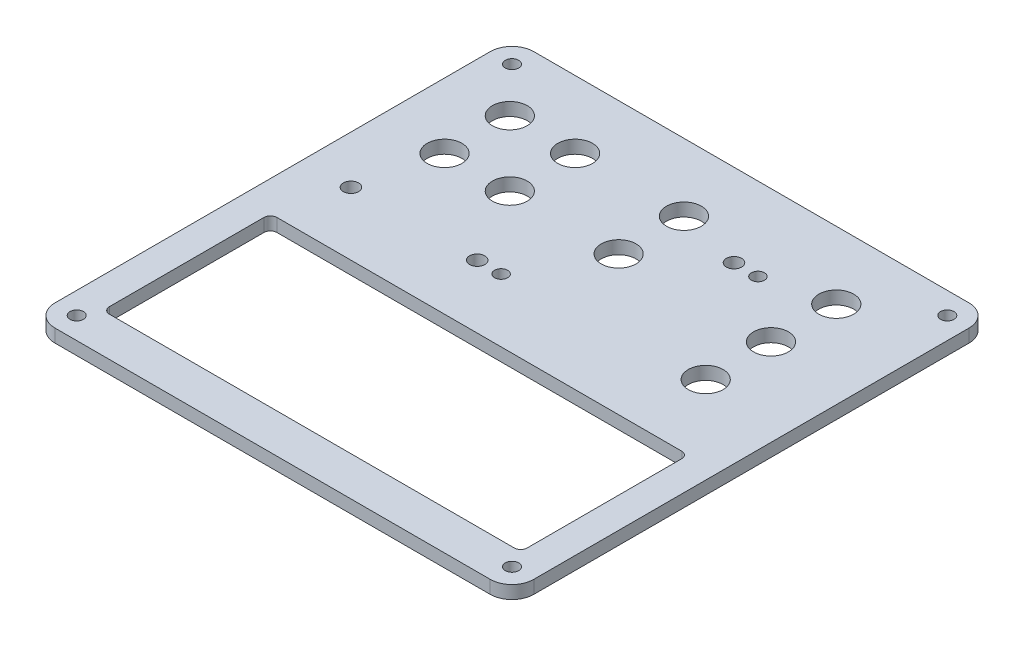
from build123d import *

# Parameters (mm, degrees)
SKETCH1_W           = 110
SKETCH1_H           = 110
SKETCH1_R           = 1.55
BOSS_EXTRUDE1_DEPTH = 3
FILLET1_R           = 5
SKETCH2_W           = 96
SKETCH2_H           = 38.5
CUT_EXTRUDE1_DEPTH  = 78.839578622
FILLET2_R           = 1.5
SKETCH3_R           = 4
CUT_EXTRUDE2_DEPTH  = 78.839578622
SKETCH4_R           = 1.75
SKETCH4_R_2         = 1.5
CUT_EXTRUDE3_DEPTH  = 78.839578622


with BuildPart() as part:
    # Sketch1 → Boss-Extrude1 (new body)
    with BuildSketch(Plane(origin=(0, 0, 0), x_dir=(1, 0, 0), z_dir=(0, 1, 0))):
        Rectangle(SKETCH1_W, SKETCH1_H)
        with Locations((-50, 50)):
            Circle(SKETCH1_R, mode=Mode.SUBTRACT)
        with Locations((50, 50)):
            Circle(SKETCH1_R, mode=Mode.SUBTRACT)
        with Locations((50, -50)):
            Circle(SKETCH1_R, mode=Mode.SUBTRACT)
        with Locations((-50, -50)):
            Circle(SKETCH1_R, mode=Mode.SUBTRACT)
    extrude(amount=BOSS_EXTRUDE1_DEPTH)

    # Fillet1
    fillet1_edges = [part.edges().sort_by_distance(p)[0] for p in [
        (-55, 1.5, -55),
        (55, 1.5, -55),
        (55, 1.5, 55),
        (-55, 1.5, 55),
    ]]
    fillet(fillet1_edges, radius=FILLET1_R)

    # Sketch2 → Cut-Extrude1 (cut, through all)
    with BuildSketch(Plane(origin=(0, 3, 0), x_dir=(1, 0, 0), z_dir=(0, 1, 0))):
        with Locations((0, -26.75)):
            Rectangle(SKETCH2_W, SKETCH2_H)
    extrude(amount=-CUT_EXTRUDE1_DEPTH, mode=Mode.SUBTRACT)

    # Fillet2
    fillet2_edges = [part.edges().sort_by_distance(p)[0] for p in [
        (-48, 1.5, 46),
        (48, 1.5, 46),
        (48, 1.5, 7.5),
        (-48, 1.5, 7.5),
    ]]
    fillet(fillet2_edges, radius=FILLET2_R)

    # Sketch3 → Cut-Extrude2 (cut, through all)
    with BuildSketch(Plane(origin=(0, 3, 0), x_dir=(1, 0, 0), z_dir=(0, 1, 0))):
        with Locations((-40, 39.5)):
            Circle(SKETCH3_R)
        with Locations((-40, 24.5)):
            Circle(SKETCH3_R)
        with Locations((-25, 39.5)):
            Circle(SKETCH3_R)
        with Locations((-25, 24.5)):
            Circle(SKETCH3_R)
        with Locations((0, 39.5)):
            Circle(SKETCH3_R)
        with Locations((0, 24.5)):
            Circle(SKETCH3_R)
        with Locations((35, 39.5)):
            Circle(SKETCH3_R)
        with Locations((35, 24.5)):
            Circle(SKETCH3_R)
        with Locations((35, 9.5)):
            Circle(SKETCH3_R)
    extrude(amount=-CUT_EXTRUDE2_DEPTH, mode=Mode.SUBTRACT)

    # Sketch4 → Cut-Extrude3 (cut, through all)
    with BuildSketch(Plane(origin=(0, 3, 0), x_dir=(1, 0, 0), z_dir=(0, 1, 0))):
        with Locations((-44, 7)):
            Circle(SKETCH4_R)
        with Locations((-15, 7)):
            Circle(SKETCH4_R)
        with Locations((-9.5, 7)):
            Circle(SKETCH4_R_2)
        with Locations((15, 36)):
            Circle(SKETCH4_R)
        with Locations((20.5, 36)):
            Circle(SKETCH4_R_2)
    extrude(amount=-CUT_EXTRUDE3_DEPTH, mode=Mode.SUBTRACT)


solid = part.part
